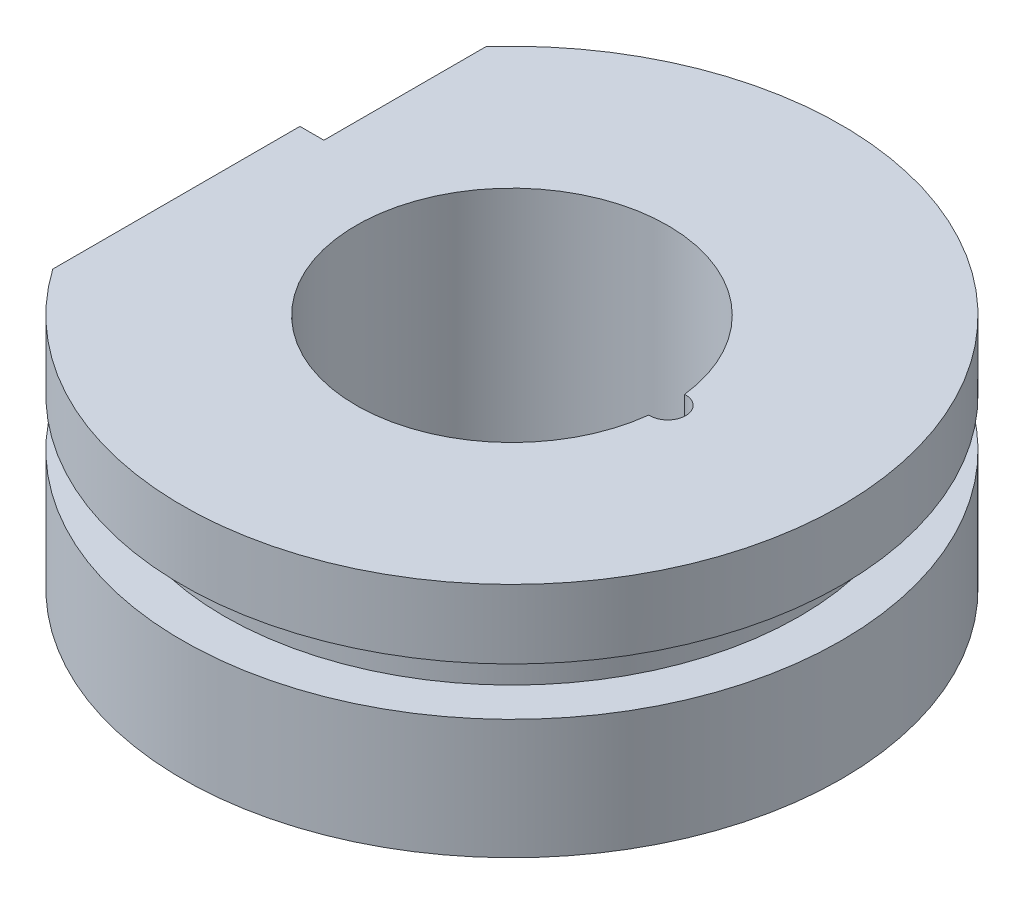
from build123d import *

# Parameters (mm, degrees)
EXTRUDE_1_DEPTH     = 19.75
SKETCH_2_R          = 13
CUT_EXTRUDE_2_DEPTH = 20.75
SKETCH_3_W          = 5
SKETCH_3_H          = 4
SKETCH_4_R          = 1.5
CUT_EXTRUDE_3_DEPTH = 20.75
CUT_EXTRUDE_4_DEPTH = 23.69


with BuildPart() as part:
    # Эскиз1 → Бобышка-Вытянуть1 (new body)
    with BuildSketch(Plane(origin=(0, 0, 0), x_dir=(1, 0, 0), z_dir=(0, 1, 0))):
        with BuildLine():
            Line((-22.5, 15.811388301), (-22.5, -15.811388301))
            ThreePointArc((-22.5, -15.811388301), (27.5, 0), (-22.5, 15.811388301))
        make_face()
    extrude(amount=EXTRUDE_1_DEPTH)

    # Эскиз2 → Вырез-Вытянуть2 (cut, through all)
    with BuildSketch(Plane(origin=(0, 0, 0), x_dir=(1, 0, 0), z_dir=(0, 1, 0))):
        Circle(SKETCH_2_R)
    extrude(amount=CUT_EXTRUDE_2_DEPTH, mode=Mode.SUBTRACT)

    # Эскиз3 → Вырез-Повернуть1 (revolve, cut)
    with BuildSketch(Plane(origin=(0, 0, 0), x_dir=(0, 0, -1), z_dir=(1, 0, 0))):
        with Locations((-26.5, 12)):
            Rectangle(SKETCH_3_W, SKETCH_3_H)
    revolve(axis=Axis((0, 0, 0), (0, 1, 0)), mode=Mode.SUBTRACT)

    # Эскиз4 → Вырез-Вытянуть3 (cut, through all)
    with BuildSketch(Plane(origin=(0, 0, 0), x_dir=(1, 0, 0), z_dir=(0, 1, 0))):
        with Locations((13, 0)):
            Circle(SKETCH_4_R)
    extrude(amount=CUT_EXTRUDE_3_DEPTH, mode=Mode.SUBTRACT)

    # Эскиз5 → Вырез-Вытянуть4 (cut, through all)
    with BuildSketch(Plane.XY.offset(-4.81)):
        Polygon((-22.5, 19.75), (-20.5, 19.75), (-22.5, 17.75), align=None)
    extrude(amount=-CUT_EXTRUDE_4_DEPTH, mode=Mode.SUBTRACT)


solid = part.part
